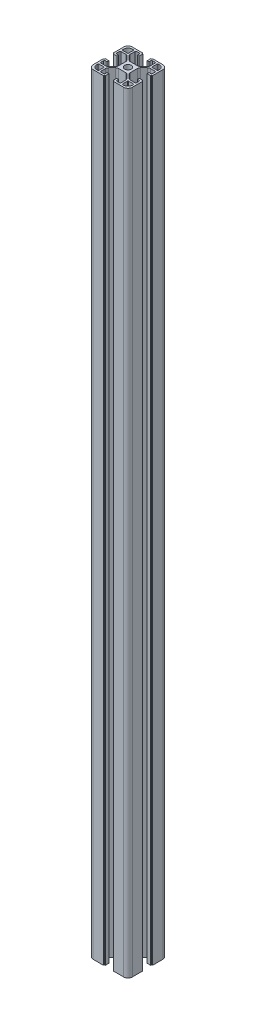
from build123d import *

# Parameters (mm, degrees)
BOSS_EXTRUDE2_DEPTH = 786


with BuildPart() as part:
    # Sketch1 → Boss-Extrude2 (new body)
    with BuildSketch(Plane(origin=(0, 0, 0), x_dir=(1, 0, 0), z_dir=(0, 1, 0))):
        with BuildLine():
            Line((84.170223908, 31.720417041), (84.170223908, 42.120417041))
            Line((84.170223908, 42.120417041), (83.570223908, 42.120417041))
            ThreePointArc((83.570223908, 42.120417041), (83.428802552, 42.178995685), (83.370223908, 42.320417041))
            Line((83.370223908, 42.320417041), (83.370223908, 42.920417041))
            ThreePointArc((83.370223908, 42.920417041), (83.311645264, 43.061838398), (83.170223908, 43.120417041))
            Line((83.170223908, 43.120417041), (79.670223908, 43.120417041))
            Line((79.670223908, 43.120417041), (79.670223908, 41.320417041))
            Line((79.670223908, 41.320417041), (81.370223908, 41.320417041))
            ThreePointArc((81.370223908, 41.320417041), (82.077330689, 41.027523823), (82.370223908, 40.320417041))
            Line((82.370223908, 40.320417041), (82.370223908, 37.970417041))
            ThreePointArc((82.370223908, 37.970417041), (82.077330689, 37.26331026), (81.370223908, 36.970417041))
            Line((81.370223908, 36.970417041), (76.723524767, 36.970417041))
            ThreePointArc((76.723524767, 36.970417041), (75.57547447, 37.198778444), (74.602204423, 37.849096698))
            Line((74.602204423, 37.849096698), (71.048903564, 41.402397557))
            ThreePointArc((71.048903564, 41.402397557), (70.39858531, 42.375667603), (70.170223908, 43.5237179))
            Line((70.170223908, 43.5237179), (70.170223908, 50.917116183))
            ThreePointArc((70.170223908, 50.917116183), (70.39858531, 52.06516648), (71.048903564, 53.038436526))
            Line((71.048903564, 53.038436526), (74.602204423, 56.591737385))
            ThreePointArc((74.602204423, 56.591737385), (75.57547447, 57.242055639), (76.723524767, 57.470417041))
            Line((76.723524767, 57.470417041), (81.370223908, 57.470417041))
            ThreePointArc((81.370223908, 57.470417041), (82.077330689, 57.177523823), (82.370223908, 56.470417041))
            Line((82.370223908, 56.470417041), (82.370223908, 54.120417041))
            ThreePointArc((82.370223908, 54.120417041), (82.077330689, 53.41331026), (81.370223908, 53.120417041))
            Line((81.370223908, 53.120417041), (79.670223908, 53.120417041))
            Line((79.670223908, 53.120417041), (79.670223908, 51.320417041))
            Line((79.670223908, 51.320417041), (83.170223908, 51.320417041))
            ThreePointArc((83.170223908, 51.320417041), (83.311645264, 51.378995685), (83.370223908, 51.520417041))
            Line((83.370223908, 51.520417041), (83.370223908, 52.120417041))
            ThreePointArc((83.370223908, 52.120417041), (83.428802552, 52.261838398), (83.570223908, 52.320417041))
            Line((83.570223908, 52.320417041), (84.170223908, 52.320417041))
            Line((84.170223908, 52.320417041), (84.170223908, 62.720417041))
            ThreePointArc((84.170223908, 62.720417041), (82.852204423, 65.902397557), (79.670223908, 67.220417041))
            Line((79.670223908, 67.220417041), (69.270223908, 67.220417041))
            Line((69.270223908, 67.220417041), (69.270223908, 66.420417041))
            Line((69.270223908, 66.420417041), (68.470223908, 66.420417041))
            ThreePointArc((68.470223908, 66.420417041), (68.328802552, 66.361838398), (68.270223908, 66.220417041))
            Line((68.270223908, 66.220417041), (68.270223908, 62.720417041))
            Line((68.270223908, 62.720417041), (70.070223908, 62.720417041))
            Line((70.070223908, 62.720417041), (70.070223908, 64.420417041))
            ThreePointArc((70.070223908, 64.420417041), (70.363117127, 65.127523823), (71.070223908, 65.420417041))
            Line((71.070223908, 65.420417041), (73.420223908, 65.420417041))
            ThreePointArc((73.420223908, 65.420417041), (74.127330689, 65.127523823), (74.420223908, 64.420417041))
            Line((74.420223908, 64.420417041), (74.420223908, 59.7737179))
            ThreePointArc((74.420223908, 59.7737179), (74.191862505, 58.625667603), (73.541544251, 57.652397557))
            Line((73.541544251, 57.652397557), (69.988243393, 54.099096698))
            ThreePointArc((69.988243393, 54.099096698), (69.014973346, 53.448778444), (67.866923049, 53.220417041))
            Line((67.866923049, 53.220417041), (60.473524767, 53.220417041))
            ThreePointArc((60.473524767, 53.220417041), (59.32547447, 53.448778444), (58.352204423, 54.099096698))
            Line((58.352204423, 54.099096698), (54.798903564, 57.652397557))
            ThreePointArc((54.798903564, 57.652397557), (54.14858531, 58.625667603), (53.920223908, 59.7737179))
            Line((53.920223908, 59.7737179), (53.920223908, 64.420417041))
            ThreePointArc((53.920223908, 64.420417041), (54.213117127, 65.127523823), (54.920223908, 65.420417041))
            Line((54.920223908, 65.420417041), (57.270223908, 65.420417041))
            ThreePointArc((57.270223908, 65.420417041), (57.977330689, 65.127523823), (58.270223908, 64.420417041))
            Line((58.270223908, 64.420417041), (58.270223908, 62.720417041))
            Line((58.270223908, 62.720417041), (60.070223908, 62.720417041))
            Line((60.070223908, 62.720417041), (60.070223908, 66.420417041))
            Line((60.070223908, 66.420417041), (59.270223908, 66.420417041))
            ThreePointArc((59.270223908, 66.420417041), (59.128802552, 66.478995685), (59.070223908, 66.620417041))
            Line((59.070223908, 66.620417041), (59.070223908, 67.220417041))
            Line((59.070223908, 67.220417041), (48.670223908, 67.220417041))
            ThreePointArc((48.670223908, 67.220417041), (45.488243393, 65.902397557), (44.170223908, 62.720417041))
            Line((44.170223908, 62.720417041), (44.170223908, 52.320417041))
            Line((44.170223908, 52.320417041), (44.770223908, 52.320417041))
            ThreePointArc((44.770223908, 52.320417041), (44.911645264, 52.261838398), (44.970223908, 52.120417041))
            Line((44.970223908, 52.120417041), (44.970223908, 51.520417041))
            ThreePointArc((44.970223908, 51.520417041), (45.028802552, 51.378995685), (45.170223908, 51.320417041))
            Line((45.170223908, 51.320417041), (48.670223908, 51.320417041))
            Line((48.670223908, 51.320417041), (48.670223908, 53.120417041))
            Line((48.670223908, 53.120417041), (46.970223908, 53.120417041))
            ThreePointArc((46.970223908, 53.120417041), (46.263117127, 53.41331026), (45.970223908, 54.120417041))
            Line((45.970223908, 54.120417041), (45.970223908, 56.470417041))
            ThreePointArc((45.970223908, 56.470417041), (46.263117127, 57.177523823), (46.970223908, 57.470417041))
            Line((46.970223908, 57.470417041), (51.616923049, 57.470417041))
            ThreePointArc((51.616923049, 57.470417041), (52.764973346, 57.242055639), (53.738243393, 56.591737385))
            Line((53.738243393, 56.591737385), (57.291544251, 53.038436526))
            ThreePointArc((57.291544251, 53.038436526), (57.941862505, 52.06516648), (58.170223908, 50.917116183))
            Line((58.170223908, 50.917116183), (58.170223908, 43.5237179))
            ThreePointArc((58.170223908, 43.5237179), (57.941862505, 42.375667603), (57.291544251, 41.402397557))
            Line((57.291544251, 41.402397557), (53.738243393, 37.849096698))
            ThreePointArc((53.738243393, 37.849096698), (52.764973346, 37.198778444), (51.616923049, 36.970417041))
            Line((51.616923049, 36.970417041), (46.970223908, 36.970417041))
            ThreePointArc((46.970223908, 36.970417041), (46.263117127, 37.26331026), (45.970223908, 37.970417041))
            Line((45.970223908, 37.970417041), (45.970223908, 40.320417041))
            ThreePointArc((45.970223908, 40.320417041), (46.263117127, 41.027523823), (46.970223908, 41.320417041))
            Line((46.970223908, 41.320417041), (48.670223908, 41.320417041))
            Line((48.670223908, 41.320417041), (48.670223908, 43.120417041))
            Line((48.670223908, 43.120417041), (45.170223908, 43.120417041))
            ThreePointArc((45.170223908, 43.120417041), (45.028802552, 43.061838398), (44.970223908, 42.920417041))
            Line((44.970223908, 42.920417041), (44.970223908, 42.320417041))
            ThreePointArc((44.970223908, 42.320417041), (44.911645264, 42.178995685), (44.770223908, 42.120417041))
            Line((44.770223908, 42.120417041), (44.170223908, 42.120417041))
            Line((44.170223908, 42.120417041), (44.170223908, 31.720417041))
            ThreePointArc((44.170223908, 31.720417041), (45.488243393, 28.538436526), (48.670223908, 27.220417041))
            Line((48.670223908, 27.220417041), (59.070223908, 27.220417041))
            Line((59.070223908, 27.220417041), (59.070223908, 27.820417041))
            ThreePointArc((59.070223908, 27.820417041), (59.128802552, 27.961838398), (59.270223908, 28.020417041))
            Line((59.270223908, 28.020417041), (59.870223908, 28.020417041))
            ThreePointArc((59.870223908, 28.020417041), (60.011645264, 28.078995685), (60.070223908, 28.220417041))
            Line((60.070223908, 28.220417041), (60.070223908, 31.720417041))
            Line((60.070223908, 31.720417041), (58.270223908, 31.720417041))
            Line((58.270223908, 31.720417041), (58.270223908, 30.020417041))
            ThreePointArc((58.270223908, 30.020417041), (57.977330689, 29.31331026), (57.270223908, 29.020417041))
            Line((57.270223908, 29.020417041), (54.920223908, 29.020417041))
            ThreePointArc((54.920223908, 29.020417041), (54.213117127, 29.31331026), (53.920223908, 30.020417041))
            Line((53.920223908, 30.020417041), (53.920223908, 34.667116183))
            ThreePointArc((53.920223908, 34.667116183), (54.14858531, 35.81516648), (54.798903564, 36.788436526))
            Line((54.798903564, 36.788436526), (58.352204423, 40.341737385))
            ThreePointArc((58.352204423, 40.341737385), (59.32547447, 40.992055639), (60.473524767, 41.220417041))
            Line((60.473524767, 41.220417041), (67.866923049, 41.220417041))
            ThreePointArc((67.866923049, 41.220417041), (69.014973346, 40.992055639), (69.988243393, 40.341737385))
            Line((69.988243393, 40.341737385), (73.541544251, 36.788436526))
            ThreePointArc((73.541544251, 36.788436526), (74.191862505, 35.81516648), (74.420223908, 34.667116183))
            Line((74.420223908, 34.667116183), (74.420223908, 30.020417041))
            ThreePointArc((74.420223908, 30.020417041), (74.127330689, 29.31331026), (73.420223908, 29.020417041))
            Line((73.420223908, 29.020417041), (71.070223908, 29.020417041))
            ThreePointArc((71.070223908, 29.020417041), (70.363117127, 29.31331026), (70.070223908, 30.020417041))
            Line((70.070223908, 30.020417041), (70.070223908, 31.720417041))
            Line((70.070223908, 31.720417041), (68.270223908, 31.720417041))
            Line((68.270223908, 31.720417041), (68.270223908, 28.220417041))
            ThreePointArc((68.270223908, 28.220417041), (68.328802552, 28.078995685), (68.470223908, 28.020417041))
            Line((68.470223908, 28.020417041), (69.070223908, 28.020417041))
            ThreePointArc((69.070223908, 28.020417041), (69.211645264, 27.961838398), (69.270223908, 27.820417041))
            Line((69.270223908, 27.820417041), (69.270223908, 27.220417041))
            Line((69.270223908, 27.220417041), (79.670223908, 27.220417041))
            ThreePointArc((79.670223908, 27.220417041), (82.852204423, 28.538436526), (84.170223908, 31.720417041))
        make_face()
        with BuildLine():
            Line((82.370223908, 34.670417041), (82.370223908, 33.520417041))
            ThreePointArc((82.370223908, 33.520417041), (81.052204423, 30.338436526), (77.870223908, 29.020417041))
            Line((77.870223908, 29.020417041), (76.720223908, 29.020417041))
            ThreePointArc((76.720223908, 29.020417041), (76.366670517, 29.166863651), (76.220223908, 29.520417041))
            Line((76.220223908, 29.520417041), (76.220223908, 34.670417041))
            ThreePointArc((76.220223908, 34.670417041), (76.366670517, 35.023970432), (76.720223908, 35.170417041))
            Line((76.720223908, 35.170417041), (81.870223908, 35.170417041))
            ThreePointArc((81.870223908, 35.170417041), (82.223777298, 35.023970432), (82.370223908, 34.670417041))
        make_face(mode=Mode.SUBTRACT)
        with BuildLine():
            Line((51.620223908, 29.020417041), (50.470223908, 29.020417041))
            ThreePointArc((50.470223908, 29.020417041), (47.288243393, 30.338436526), (45.970223908, 33.520417041))
            Line((45.970223908, 33.520417041), (45.970223908, 34.670417041))
            ThreePointArc((45.970223908, 34.670417041), (46.116670517, 35.023970432), (46.470223908, 35.170417041))
            Line((46.470223908, 35.170417041), (51.620223908, 35.170417041))
            ThreePointArc((51.620223908, 35.170417041), (51.973777298, 35.023970432), (52.120223908, 34.670417041))
            Line((52.120223908, 34.670417041), (52.120223908, 29.520417041))
            ThreePointArc((52.120223908, 29.520417041), (51.973777298, 29.166863651), (51.620223908, 29.020417041))
        make_face(mode=Mode.SUBTRACT)
        with BuildLine():
            Line((45.970223908, 59.770417041), (45.970223908, 60.920417041))
            ThreePointArc((45.970223908, 60.920417041), (47.288243393, 64.102397557), (50.470223908, 65.420417041))
            Line((50.470223908, 65.420417041), (51.620223908, 65.420417041))
            ThreePointArc((51.620223908, 65.420417041), (51.973777298, 65.273970432), (52.120223908, 64.920417041))
            Line((52.120223908, 64.920417041), (52.120223908, 59.770417041))
            ThreePointArc((52.120223908, 59.770417041), (51.973777298, 59.416863651), (51.620223908, 59.270417041))
            Line((51.620223908, 59.270417041), (46.470223908, 59.270417041))
            ThreePointArc((46.470223908, 59.270417041), (46.116670517, 59.416863651), (45.970223908, 59.770417041))
        make_face(mode=Mode.SUBTRACT)
        with BuildLine():
            Line((76.720223908, 65.420417041), (77.870223908, 65.420417041))
            ThreePointArc((77.870223908, 65.420417041), (81.052204423, 64.102397557), (82.370223908, 60.920417041))
            Line((82.370223908, 60.920417041), (82.370223908, 59.770417041))
            ThreePointArc((82.370223908, 59.770417041), (82.223777298, 59.416863651), (81.870223908, 59.270417041))
            Line((81.870223908, 59.270417041), (76.720223908, 59.270417041))
            ThreePointArc((76.720223908, 59.270417041), (76.366670517, 59.416863651), (76.220223908, 59.770417041))
            Line((76.220223908, 59.770417041), (76.220223908, 64.920417041))
            ThreePointArc((76.220223908, 64.920417041), (76.366670517, 65.273970432), (76.720223908, 65.420417041))
        make_face(mode=Mode.SUBTRACT)
        with BuildLine():
            ThreePointArc((60.770223908, 47.220417041), (64.170223908, 43.820417041), (67.570223908, 47.220417041))
            ThreePointArc((67.570223908, 47.220417041), (64.170223908, 50.620417041), (60.770223908, 47.220417041))
        make_face(mode=Mode.SUBTRACT)
    extrude(amount=BOSS_EXTRUDE2_DEPTH)


solid = part.part
